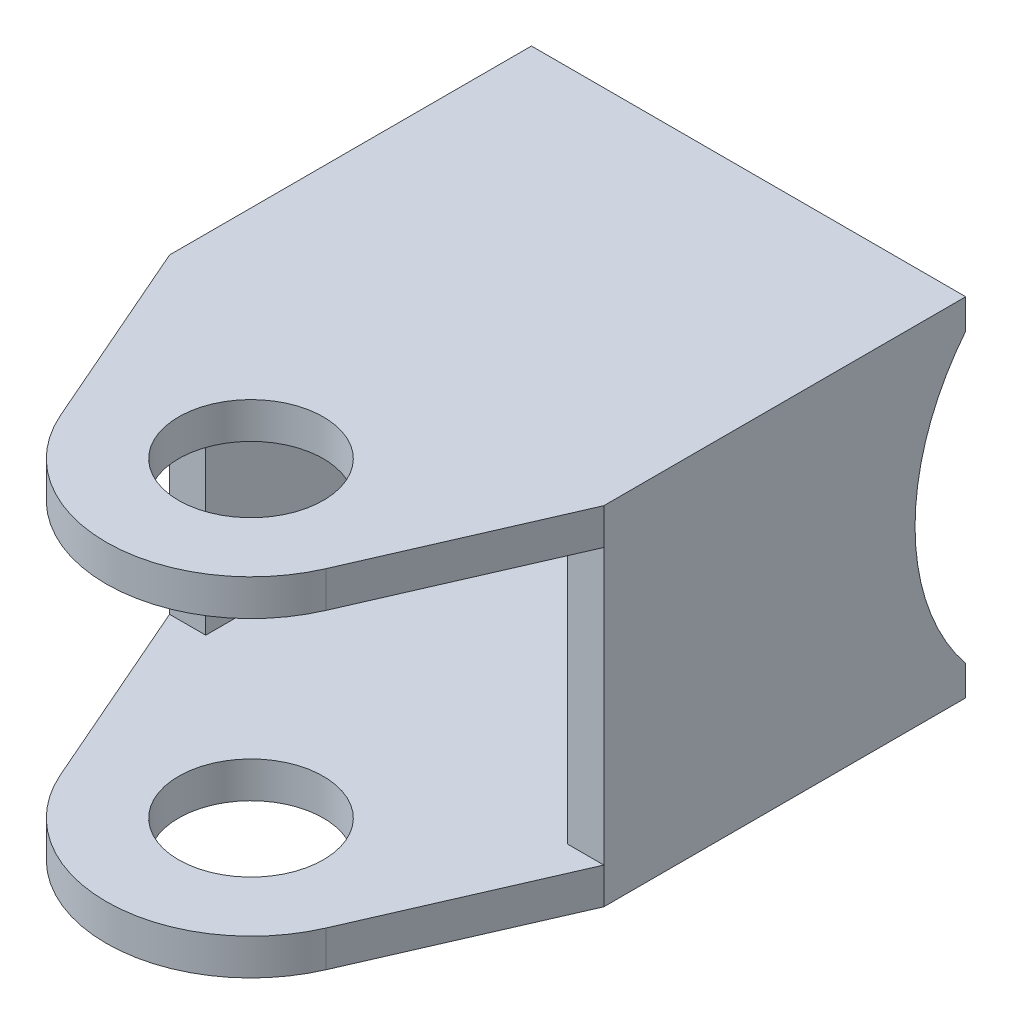
from build123d import *

# Parameters (mm, degrees)
BOSS_EXTRUDE1_START     = 7.6
SKETCH1_R               = 4
BOSS_EXTRUDE1_DEPTH     = 2
BOSS_EXTRUDE2_START     = -7.6
SKETCH1_2_R             = 4
BOSS_EXTRUDE2_DEPTH     = 2
BOSS_EXTRUDE3_START     = -7.6
SKETCH2_W               = 2
SKETCH2_H               = 20
BOSS_EXTRUDE3_DEPTH     = 15.2
SKETCH3_R               = 12.7
CUT_EXTRUDE1_DEPTH      = 13
CUT_EXTRUDE1_DEPTH_BACK = 13


with BuildPart() as part:
    # Sketch1 → Boss-Extrude1 (new body)
    with BuildSketch(Plane(origin=(0, 0, 0), x_dir=(1, 0, 0), z_dir=(0, 1, 0)).offset(BOSS_EXTRUDE1_START)):
        with BuildLine():
            Line((7.06, 27.5), (12, 27.5))
            Line((12, 27.5), (12, 7.5))
            Line((12, 7.5), (7.332619485, -3.198857842))
            ThreePointArc((7.332619485, -3.198857842), (0, -8), (-7.332619485, -3.198857842))
            Line((-7.332619485, -3.198857842), (-12, 7.5))
            Line((-12, 7.5), (-12, 22.888900714))
            Line((-12, 22.888900714), (-12, 27.5))
            Line((-12, 27.5), (7.06, 27.5))
        make_face()
        Circle(SKETCH1_R, mode=Mode.SUBTRACT)
    extrude(amount=BOSS_EXTRUDE1_DEPTH)



with BuildPart() as body_2:
    # Sketch1_2 → Boss-Extrude2 (new body)
    with BuildSketch(Plane(origin=(0, 0, 0), x_dir=(1, 0, 0), z_dir=(0, 1, 0)).offset(BOSS_EXTRUDE2_START)):
        with BuildLine():
            Line((7.06, 27.5), (12, 27.5))
            Line((12, 27.5), (12, 7.5))
            Line((12, 7.5), (7.332619485, -3.198857842))
            ThreePointArc((7.332619485, -3.198857842), (0, -8), (-7.332619485, -3.198857842))
            Line((-7.332619485, -3.198857842), (-12, 7.5))
            Line((-12, 7.5), (-12, 22.888900714))
            Line((-12, 22.888900714), (-12, 27.5))
            Line((-12, 27.5), (7.06, 27.5))
        make_face()
        Circle(SKETCH1_2_R, mode=Mode.SUBTRACT)
    extrude(amount=-BOSS_EXTRUDE2_DEPTH)


with BuildPart() as part_1:
    add(part.part)

    add(body_2.part)  # Boss-Extrude3 merges body 2
    # Sketch2 → Boss-Extrude3 (add)
    with BuildSketch(Plane(origin=(0, 0, 0), x_dir=(1, 0, 0), z_dir=(0, 1, 0)).offset(BOSS_EXTRUDE3_START)):
        with Locations((-11, 17.5)):
            Rectangle(SKETCH2_W, SKETCH2_H)
        with Locations((11, 17.5)):
            Rectangle(SKETCH2_W, SKETCH2_H)
    extrude(amount=BOSS_EXTRUDE3_DEPTH)

    # Sketch3 → Cut-Extrude1 (cut, two sides)
    with BuildSketch(Plane(origin=(0, 0, 0), x_dir=(0, 0, -1), z_dir=(1, 0, 0))) as cut_extrude1_sk:
        with Locations((37.4, 0)):
            Circle(SKETCH3_R)
    extrude(amount=CUT_EXTRUDE1_DEPTH, mode=Mode.SUBTRACT)
    extrude(cut_extrude1_sk.sketch, amount=-CUT_EXTRUDE1_DEPTH_BACK, mode=Mode.SUBTRACT)


solid = part_1.part
